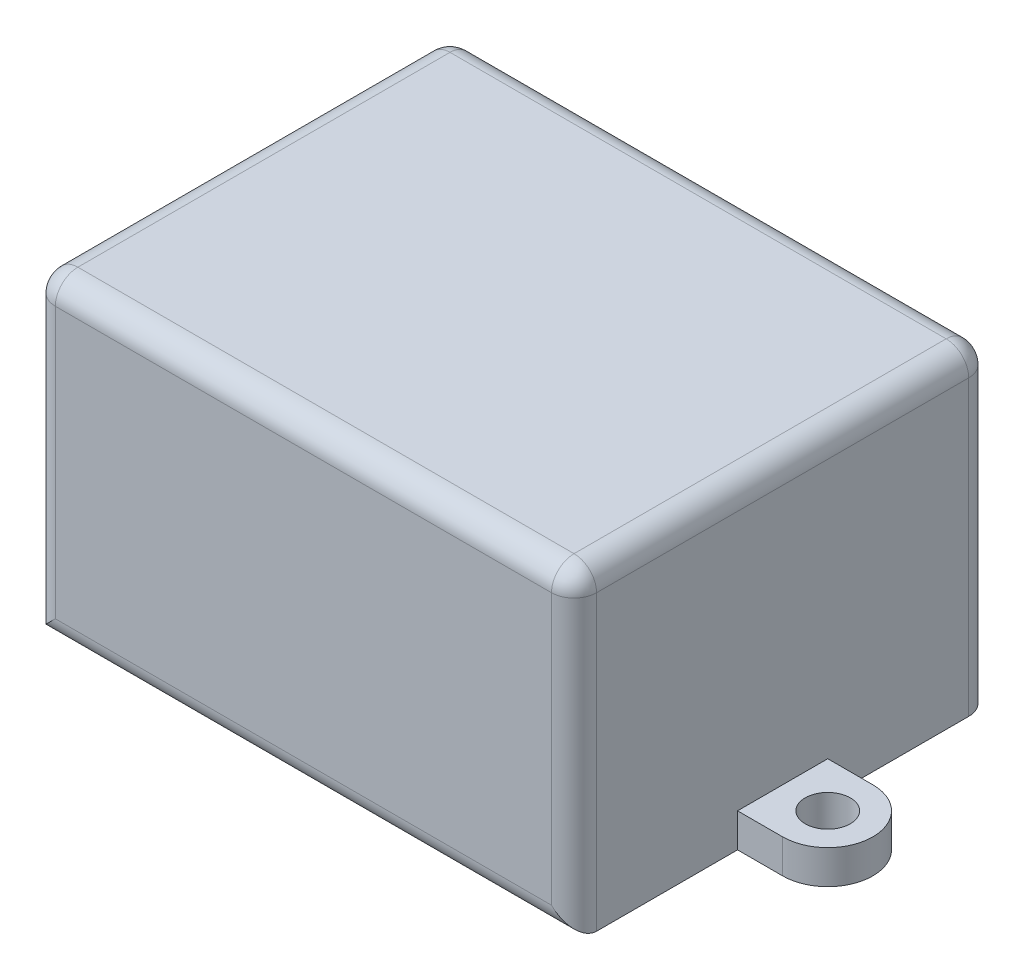
from build123d import *

# Parameters (mm, degrees)
SKETCH_1_W      = 48
SKETCH_1_H      = 28
EXTRUDE_1_DEPTH = 37
FILLET_1_R      = 2
SKETCH_2_R      = 2
EXTRUDE_2_DEPTH = 3


with BuildPart() as part:
    # 草图1 → 凸台-拉伸1 (new body)
    with BuildSketch(Plane.XY):
        with Locations((24, 14)):
            Rectangle(SKETCH_1_W, SKETCH_1_H)
    extrude(amount=EXTRUDE_1_DEPTH)

    # 圆角1
    fillet_1_edges = [part.edges().sort_by_distance(p)[0] for p in [
        (48, 14, 37),
        (24, 28, 37),
        (0, 14, 37),
        (24, 28, 0),
        (48, 14, 0),
        (0, 14, 0),
        (0, 28, 18.5),
        (48, 28, 18.5),
        (24, 0, 37),
    ]]
    fillet(fillet_1_edges, radius=FILLET_1_R)

    # 草图2 → 凸台-拉伸2 (add)
    with BuildSketch(Plane.XZ):
        with BuildLine():
            Line((-4, 22.5), (52, 22.5))
            ThreePointArc((52, 22.5), (56, 18.5), (52, 14.5))
            Line((52, 14.5), (-4, 14.5))
            ThreePointArc((-4, 14.5), (-8, 18.5), (-4, 22.5))
        make_face()
        with Locations((-4, 18.5)):
            Circle(SKETCH_2_R, mode=Mode.SUBTRACT)
        with Locations((52, 18.5)):
            Circle(SKETCH_2_R, mode=Mode.SUBTRACT)
    extrude(amount=-EXTRUDE_2_DEPTH)


solid = part.part
